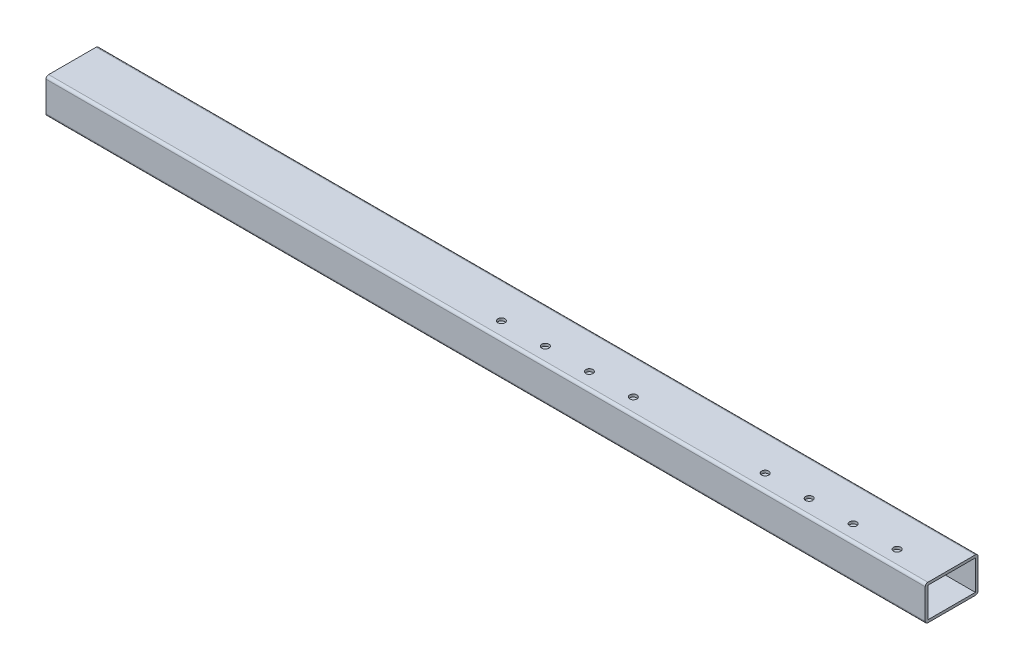
from build123d import *

# Parameters (mm, degrees)
SKETCH_1_W          = 54
SKETCH_1_H          = 34
EXTRUDE_1_DEPTH     = 1000
SKETCH_2_R          = 4.05
CUT_EXTRUDE_1_DEPTH = 41


with BuildPart() as part:
    # Эскиз1 → Вытянуть-Тонкостенный1 (new body)
    with BuildSketch(Plane(origin=(0, 0, 0), x_dir=(0, 0, -1), z_dir=(1, 0, 0))):
        with BuildLine():
            Line((30, 17), (30, -17))
            ThreePointArc((30, -17), (29.121320344, -19.121320344), (27, -20))
            Line((27, -20), (-27, -20))
            ThreePointArc((-27, -20), (-29.121320344, -19.121320344), (-30, -17))
            Line((-30, -17), (-30, 17))
            ThreePointArc((-30, 17), (-29.121320344, 19.121320344), (-27, 20))
            Line((-27, 20), (27, 20))
            ThreePointArc((27, 20), (29.121320344, 19.121320344), (30, 17))
        make_face()
        Rectangle(SKETCH_1_W, SKETCH_1_H, mode=Mode.SUBTRACT)
    extrude(amount=EXTRUDE_1_DEPTH)

    # Эскиз2 → Вырез-Вытянуть1 (cut, through all)
    with BuildSketch(Plane(origin=(0, 20, 0), x_dir=(1, 0, 0), z_dir=(0, 1, 0))):
        with Locations((950, -12)):
            Circle(SKETCH_2_R)
        with Locations((900, -12)):
            Circle(SKETCH_2_R)
        with Locations((850, -12)):
            Circle(SKETCH_2_R)
        with Locations((800, -12)):
            Circle(SKETCH_2_R)
        with Locations((650, -12)):
            Circle(SKETCH_2_R)
        with Locations((600, -12)):
            Circle(SKETCH_2_R)
        with Locations((550, -12)):
            Circle(SKETCH_2_R)
        with Locations((500, -12)):
            Circle(SKETCH_2_R)
    extrude(amount=-CUT_EXTRUDE_1_DEPTH, mode=Mode.SUBTRACT)


solid = part.part
